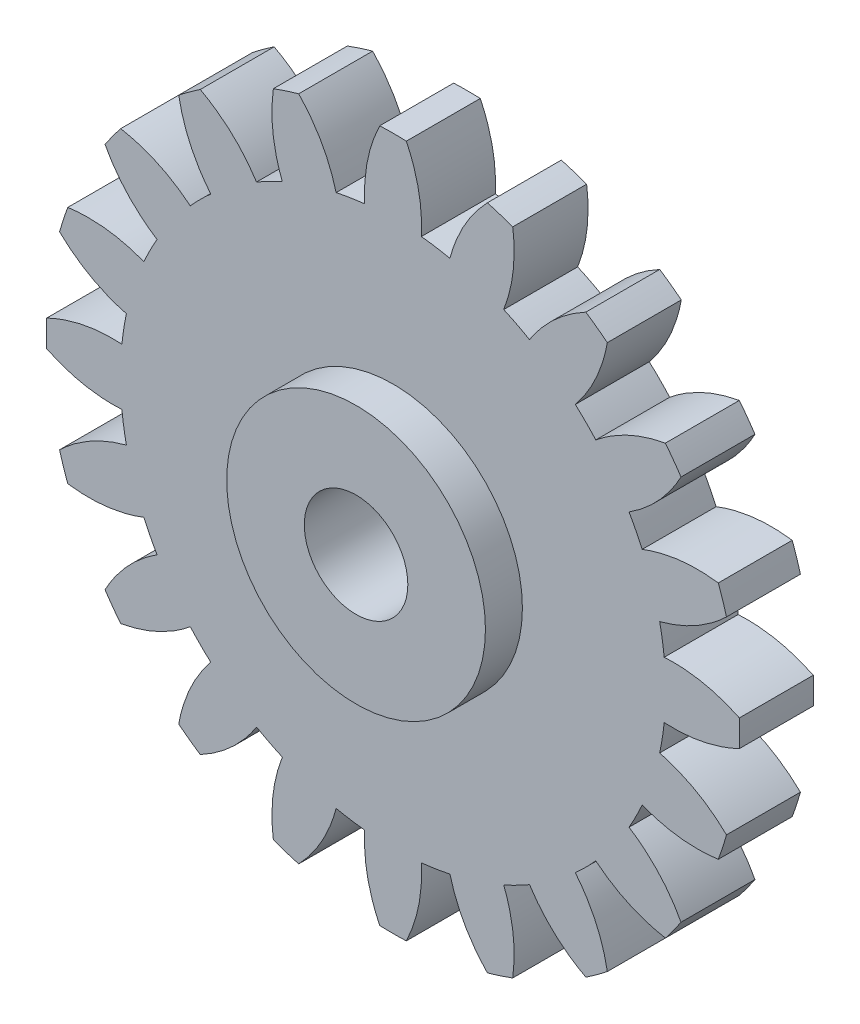
from build123d import *

# Parameters (mm, degrees)
EXTRUDE_1_DEPTH          = 0.5
SKETCH_2_R               = 1.75
EXTRUDE_2_DEPTH          = 0.5
SKETCH_3_R               = 1.75
EXTRUDE_3_DEPTH          = 0.5
SKETCH_4_R               = 0.7
CUT_EXTRUDE_1_DEPTH      = 2
CUT_EXTRUDE_1_DEPTH_BACK = 2


with BuildPart() as part:
    # 草图1 → 凸台-拉伸1 (new body, symmetric)
    with BuildSketch(Plane.XY):
        with BuildLine():
            ThreePointArc((-0.38262396, 3.667595282), (-0.57685209, 3.642100756), (-0.76945226, 3.606327699))
            add(Edge.make_bspline(
                [(-1.276290582, 4.510403374), (-0.905965718, 4.123290839), (-0.76945226, 3.606327699)],
                knots=[0, 0, 0, 1, 1, 1], degree=2))
            ThreePointArc((-1.276290582, 4.510403374), (-1.448517161, 4.45807742), (-1.618607815, 4.399177763))
            add(Edge.make_bspline(
                [(-1.618607815, 4.399177763), (-1.690667884, 3.86832565), (-1.497246281, 3.369853086)],
                knots=[0, 0, 0, 1, 1, 1], degree=2))
            ThreePointArc((-1.497246281, 3.369853086), (-1.674089968, 3.285586558), (-1.846209132, 3.192047633))
            add(Edge.make_bspline(
                [(-2.607615769, 3.895253041), (-2.135791542, 3.641523818), (-1.846209132, 3.192047633)],
                knots=[0, 0, 0, 1, 1, 1], degree=2))
            ThreePointArc((-2.607615769, 3.895253041), (-2.75524337, 3.792267161), (-2.8988082, 3.683689356))
            add(Edge.make_bspline(
                [(-2.8988082, 3.683689356), (-2.803299073, 3.156551209), (-2.465307704, 2.742246191)],
                knots=[0, 0, 0, 1, 1, 1], degree=2))
            ThreePointArc((-2.465307704, 2.742246191), (-2.607456256, 2.607456256), (-2.742246191, 2.465307704))
            add(Edge.make_bspline(
                [(-3.683689356, 2.8988082), (-3.156551209, 2.803299073), (-2.742246191, 2.465307704)],
                knots=[0, 0, 0, 1, 1, 1], degree=2))
            ThreePointArc((-3.683689356, 2.8988082), (-3.792267161, 2.75524337), (-3.895253041, 2.607615769))
            add(Edge.make_bspline(
                [(-3.895253041, 2.607615769), (-3.641523818, 2.135791542), (-3.192047633, 1.846209132)],
                knots=[0, 0, 0, 1, 1, 1], degree=2))
            ThreePointArc((-3.192047633, 1.846209132), (-3.285586558, 1.674089968), (-3.369853086, 1.497246281))
            add(Edge.make_bspline(
                [(-4.399177763, 1.618607815), (-3.86832565, 1.690667884), (-3.369853086, 1.497246281)],
                knots=[0, 0, 0, 1, 1, 1], degree=2))
            ThreePointArc((-4.399177763, 1.618607815), (-4.45807742, 1.448517161), (-4.510403374, 1.276290582))
            add(Edge.make_bspline(
                [(-4.510403374, 1.276290582), (-4.123290839, 0.905965718), (-3.606327699, 0.76945226)],
                knots=[0, 0, 0, 1, 1, 1], degree=2))
            ThreePointArc((-3.606327699, 0.76945226), (-3.642100756, 0.57685209), (-3.667595282, 0.38262396))
            add(Edge.make_bspline(
                [(-4.684044, 0.179966819), (-4.201441424, 0.412542342), (-3.667595282, 0.38262396)],
                knots=[0, 0, 0, 1, 1, 1], degree=2))
            ThreePointArc((-4.684044, 0.179966819), (-4.6875, 0), (-4.684044, -0.179966819))
            add(Edge.make_bspline(
                [(-4.684044, -0.179966819), (-4.201441424, -0.412542342), (-3.667595282, -0.38262396)],
                knots=[0, 0, 0, 1, 1, 1], degree=2))
            ThreePointArc((-3.667595282, -0.38262396), (-3.642100756, -0.57685209), (-3.606327699, -0.76945226))
            add(Edge.make_bspline(
                [(-4.510403374, -1.276290582), (-4.123290839, -0.905965718), (-3.606327699, -0.76945226)],
                knots=[0, 0, 0, 1, 1, 1], degree=2))
            ThreePointArc((-4.510403374, -1.276290582), (-4.45807742, -1.448517161), (-4.399177763, -1.618607815))
            add(Edge.make_bspline(
                [(-4.399177763, -1.618607815), (-3.86832565, -1.690667884), (-3.369853086, -1.497246281)],
                knots=[0, 0, 0, 1, 1, 1], degree=2))
            ThreePointArc((-3.369853086, -1.497246281), (-3.285586558, -1.674089968), (-3.192047633, -1.846209132))
            add(Edge.make_bspline(
                [(-3.895253041, -2.607615769), (-3.641523818, -2.135791542), (-3.192047633, -1.846209132)],
                knots=[0, 0, 0, 1, 1, 1], degree=2))
            ThreePointArc((-3.895253041, -2.607615769), (-3.792267161, -2.75524337), (-3.683689356, -2.8988082))
            add(Edge.make_bspline(
                [(-3.683689356, -2.8988082), (-3.156551209, -2.803299073), (-2.742246191, -2.465307704)],
                knots=[0, 0, 0, 1, 1, 1], degree=2))
            ThreePointArc((-2.742246191, -2.465307704), (-2.607456256, -2.607456256), (-2.465307704, -2.742246191))
            add(Edge.make_bspline(
                [(-2.8988082, -3.683689356), (-2.803299073, -3.156551209), (-2.465307704, -2.742246191)],
                knots=[0, 0, 0, 1, 1, 1], degree=2))
            ThreePointArc((-2.8988082, -3.683689356), (-2.75524337, -3.792267161), (-2.607615769, -3.895253041))
            add(Edge.make_bspline(
                [(-2.607615769, -3.895253041), (-2.135791542, -3.641523818), (-1.846209132, -3.192047633)],
                knots=[0, 0, 0, 1, 1, 1], degree=2))
            ThreePointArc((-1.846209132, -3.192047633), (-1.674089968, -3.285586558), (-1.497246281, -3.369853086))
            add(Edge.make_bspline(
                [(-1.618607815, -4.399177763), (-1.690667884, -3.86832565), (-1.497246281, -3.369853086)],
                knots=[0, 0, 0, 1, 1, 1], degree=2))
            ThreePointArc((-1.618607815, -4.399177763), (-1.448517161, -4.45807742), (-1.276290582, -4.510403374))
            add(Edge.make_bspline(
                [(-1.276290582, -4.510403374), (-0.905965718, -4.123290839), (-0.76945226, -3.606327699)],
                knots=[0, 0, 0, 1, 1, 1], degree=2))
            ThreePointArc((-0.76945226, -3.606327699), (-0.57685209, -3.642100756), (-0.38262396, -3.667595282))
            add(Edge.make_bspline(
                [(-0.179966819, -4.684044), (-0.412542342, -4.201441424), (-0.38262396, -3.667595282)],
                knots=[0, 0, 0, 1, 1, 1], degree=2))
            ThreePointArc((-0.179966819, -4.684044), (0, -4.6875), (0.179966819, -4.684044))
            add(Edge.make_bspline(
                [(0.179966819, -4.684044), (0.412542342, -4.201441424), (0.38262396, -3.667595282)],
                knots=[0, 0, 0, 1, 1, 1], degree=2))
            ThreePointArc((0.38262396, -3.667595282), (0.57685209, -3.642100756), (0.76945226, -3.606327699))
            add(Edge.make_bspline(
                [(1.276290582, -4.510403374), (0.905965718, -4.123290839), (0.76945226, -3.606327699)],
                knots=[0, 0, 0, 1, 1, 1], degree=2))
            ThreePointArc((1.276290582, -4.510403374), (1.448517161, -4.45807742), (1.618607815, -4.399177763))
            add(Edge.make_bspline(
                [(1.618607815, -4.399177763), (1.690667884, -3.86832565), (1.497246281, -3.369853086)],
                knots=[0, 0, 0, 1, 1, 1], degree=2))
            ThreePointArc((1.497246281, -3.369853086), (1.674089968, -3.285586558), (1.846209132, -3.192047633))
            add(Edge.make_bspline(
                [(2.607615769, -3.895253041), (2.135791542, -3.641523818), (1.846209132, -3.192047633)],
                knots=[0, 0, 0, 1, 1, 1], degree=2))
            ThreePointArc((2.607615769, -3.895253041), (2.75524337, -3.792267161), (2.8988082, -3.683689356))
            add(Edge.make_bspline(
                [(2.8988082, -3.683689356), (2.803299073, -3.156551209), (2.465307704, -2.742246191)],
                knots=[0, 0, 0, 1, 1, 1], degree=2))
            ThreePointArc((2.465307704, -2.742246191), (2.607456256, -2.607456256), (2.742246191, -2.465307704))
            add(Edge.make_bspline(
                [(3.683689356, -2.8988082), (3.156551209, -2.803299073), (2.742246191, -2.465307704)],
                knots=[0, 0, 0, 1, 1, 1], degree=2))
            ThreePointArc((3.683689356, -2.8988082), (3.792267161, -2.75524337), (3.895253041, -2.607615769))
            add(Edge.make_bspline(
                [(3.895253041, -2.607615769), (3.641523818, -2.135791542), (3.192047633, -1.846209132)],
                knots=[0, 0, 0, 1, 1, 1], degree=2))
            ThreePointArc((3.192047633, -1.846209132), (3.285586558, -1.674089968), (3.369853086, -1.497246281))
            add(Edge.make_bspline(
                [(4.399177763, -1.618607815), (3.86832565, -1.690667884), (3.369853086, -1.497246281)],
                knots=[0, 0, 0, 1, 1, 1], degree=2))
            ThreePointArc((4.399177763, -1.618607815), (4.45807742, -1.448517161), (4.510403374, -1.276290582))
            add(Edge.make_bspline(
                [(4.510403374, -1.276290582), (4.123290839, -0.905965718), (3.606327699, -0.76945226)],
                knots=[0, 0, 0, 1, 1, 1], degree=2))
            ThreePointArc((3.606327699, -0.76945226), (3.642100756, -0.57685209), (3.667595282, -0.38262396))
            add(Edge.make_bspline(
                [(4.684044, -0.179966819), (4.201441424, -0.412542342), (3.667595282, -0.38262396)],
                knots=[0, 0, 0, 1, 1, 1], degree=2))
            ThreePointArc((4.684044, -0.179966819), (4.6875, 0), (4.684044, 0.179966819))
            add(Edge.make_bspline(
                [(4.684044, 0.179966819), (4.201441424, 0.412542342), (3.667595282, 0.38262396)],
                knots=[0, 0, 0, 1, 1, 1], degree=2))
            ThreePointArc((3.667595282, 0.38262396), (3.642100756, 0.57685209), (3.606327699, 0.76945226))
            add(Edge.make_bspline(
                [(4.510403374, 1.276290582), (4.123290839, 0.905965718), (3.606327699, 0.76945226)],
                knots=[0, 0, 0, 1, 1, 1], degree=2))
            ThreePointArc((4.510403374, 1.276290582), (4.45807742, 1.448517161), (4.399177763, 1.618607815))
            add(Edge.make_bspline(
                [(4.399177763, 1.618607815), (3.86832565, 1.690667884), (3.369853086, 1.497246281)],
                knots=[0, 0, 0, 1, 1, 1], degree=2))
            ThreePointArc((3.369853086, 1.497246281), (3.285586558, 1.674089968), (3.192047633, 1.846209132))
            add(Edge.make_bspline(
                [(3.895253041, 2.607615769), (3.641523818, 2.135791542), (3.192047633, 1.846209132)],
                knots=[0, 0, 0, 1, 1, 1], degree=2))
            ThreePointArc((3.895253041, 2.607615769), (3.792267161, 2.75524337), (3.683689356, 2.8988082))
            add(Edge.make_bspline(
                [(3.683689356, 2.8988082), (3.156551209, 2.803299073), (2.742246191, 2.465307704)],
                knots=[0, 0, 0, 1, 1, 1], degree=2))
            ThreePointArc((2.742246191, 2.465307704), (2.607456256, 2.607456256), (2.465307704, 2.742246191))
            add(Edge.make_bspline(
                [(2.8988082, 3.683689356), (2.803299073, 3.156551209), (2.465307704, 2.742246191)],
                knots=[0, 0, 0, 1, 1, 1], degree=2))
            ThreePointArc((2.8988082, 3.683689356), (2.75524337, 3.792267161), (2.607615769, 3.895253041))
            add(Edge.make_bspline(
                [(2.607615769, 3.895253041), (2.135791542, 3.641523818), (1.846209132, 3.192047633)],
                knots=[0, 0, 0, 1, 1, 1], degree=2))
            ThreePointArc((1.846209132, 3.192047633), (1.674089968, 3.285586558), (1.497246281, 3.369853086))
            add(Edge.make_bspline(
                [(1.618607815, 4.399177763), (1.690667884, 3.86832565), (1.497246281, 3.369853086)],
                knots=[0, 0, 0, 1, 1, 1], degree=2))
            ThreePointArc((1.618607815, 4.399177763), (1.448517161, 4.45807742), (1.276290582, 4.510403374))
            add(Edge.make_bspline(
                [(1.276290582, 4.510403374), (0.905965718, 4.123290839), (0.76945226, 3.606327699)],
                knots=[0, 0, 0, 1, 1, 1], degree=2))
            ThreePointArc((0.76945226, 3.606327699), (0.57685209, 3.642100756), (0.38262396, 3.667595282))
            add(Edge.make_bspline(
                [(0.179966819, 4.684044), (0.412542342, 4.201441424), (0.38262396, 3.667595282)],
                knots=[0, 0, 0, 1, 1, 1], degree=2))
            ThreePointArc((0.179966819, 4.684044), (0, 4.6875), (-0.179966819, 4.684044))
            add(Edge.make_bspline(
                [(-0.179966819, 4.684044), (-0.412542342, 4.201441424), (-0.38262396, 3.667595282)],
                knots=[0, 0, 0, 1, 1, 1], degree=2))
        make_face()
    extrude(amount=EXTRUDE_1_DEPTH, both=True)

    # 草图2 → 凸台-拉伸2 (add)
    with BuildSketch(Plane(origin=(0, 0, -0.5), x_dir=(-1, 0, 0), z_dir=(0, 0, -1))):
        Circle(SKETCH_2_R)
    extrude(amount=EXTRUDE_2_DEPTH)

    # 草图3 → 凸台-拉伸3 (add)
    with BuildSketch(Plane.XY.offset(0.5)):
        Circle(SKETCH_3_R)
    extrude(amount=EXTRUDE_3_DEPTH)

    # 草图4 → 切除-拉伸1 (cut, two sides)
    with BuildSketch(Plane.XY) as cut_extrude_1_sk:
        Circle(SKETCH_4_R)
    extrude(amount=CUT_EXTRUDE_1_DEPTH, mode=Mode.SUBTRACT)
    extrude(cut_extrude_1_sk.sketch, amount=-CUT_EXTRUDE_1_DEPTH_BACK, mode=Mode.SUBTRACT)


solid = part.part
